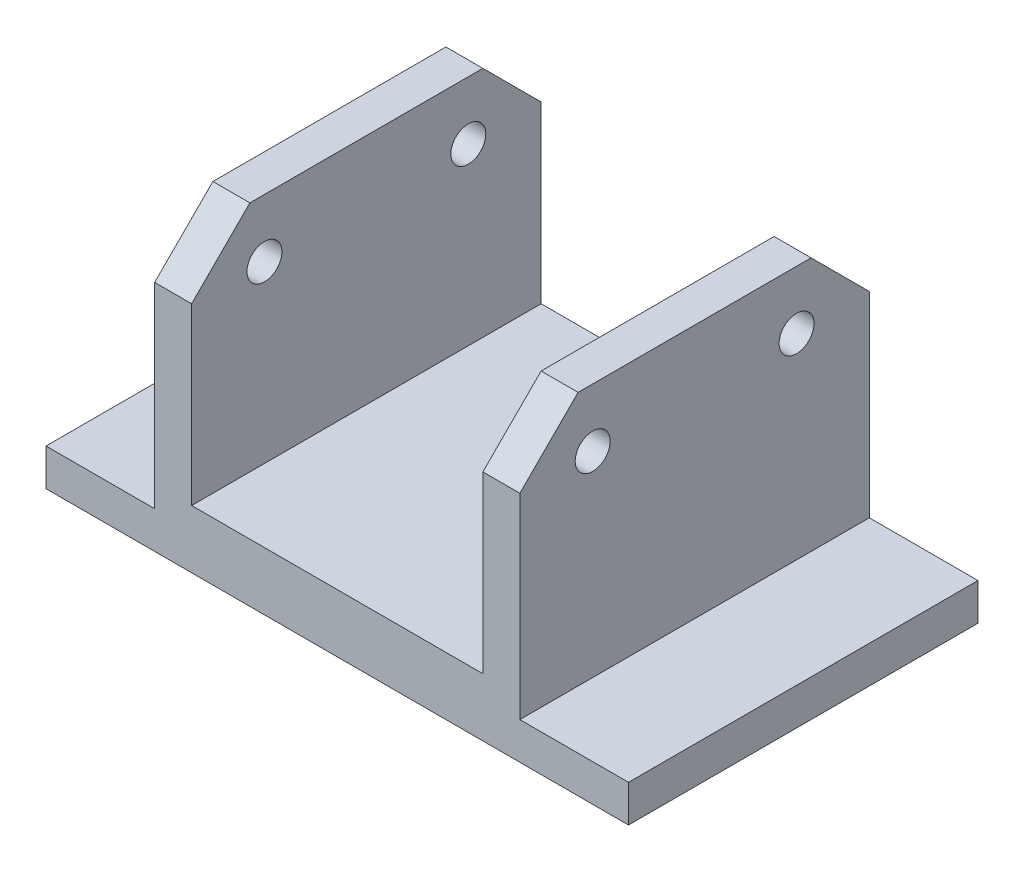
from build123d import *

# Parameters (mm, degrees)
RESSALTO_EXTRUS_O1_DEPTH = 60
CHANFRO1_SIZE            = 20
ESBO_O2_R                = 6
CORTE_EXTRUS_O1_DEPTH    = 163.7


with BuildPart() as part:
    # Esboço1 → Ressalto-extrusão1 (new body, symmetric)
    with BuildSketch(Plane.XY):
        Polygon((-100, 0), (100, 0), (100, 12.7), (62.7, 12.7), (62.7, 100), (50, 100), (50, 20), (-50, 20), (-50, 100), (-62.7, 100), (-62.7, 12.7), (-100, 12.7), align=None)
    extrude(amount=RESSALTO_EXTRUS_O1_DEPTH, both=True)

    # Chanfro1
    chanfro1_edges = [part.edges().sort_by_distance(p)[0] for p in [
        (-56.35, 100, -60),
        (56.35, 100, 60),
        (56.35, 100, -60),
        (-56.35, 100, 60),
    ]]
    chamfer(chanfro1_edges, length=CHANFRO1_SIZE)

    # Esboço2 → Corte-extrusão1 (cut, through all)
    with BuildSketch(Plane(origin=(62.7, 0, 0), x_dir=(0, 0, -1), z_dir=(1, 0, 0))):
        with Locations((-35, 80)):
            Circle(ESBO_O2_R)
        with Locations((35, 80)):
            Circle(ESBO_O2_R)
    extrude(amount=-CORTE_EXTRUS_O1_DEPTH, mode=Mode.SUBTRACT)


solid = part.part
